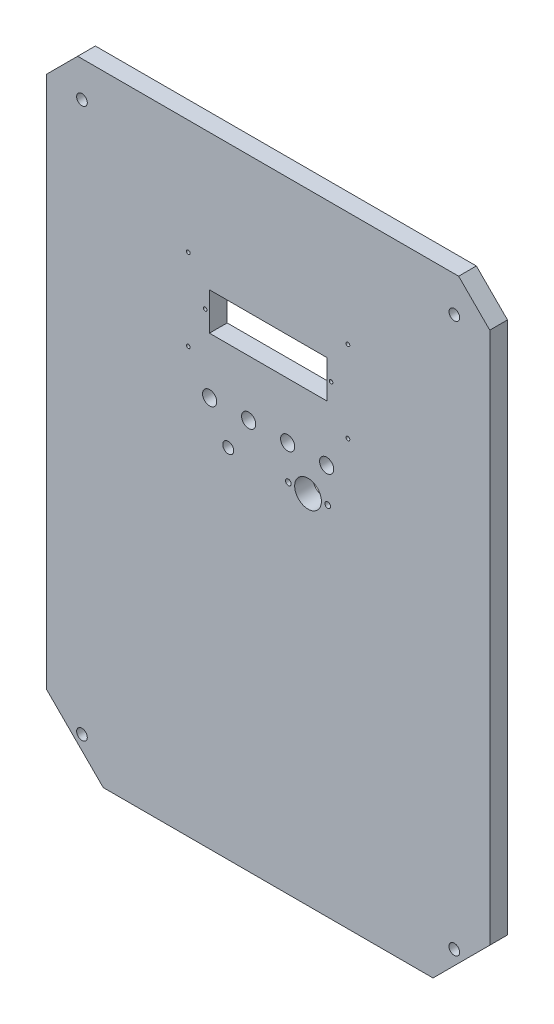
from build123d import *

# Parameters (mm, degrees)
ESQUISSE1_R        = 3
ESQUISSE1_R_2      = 1.05
ESQUISSE1_R_3      = 1
ESQUISSE1_R_4      = 7.55
ESQUISSE1_R_5      = 4
ESQUISSE1_R_6      = 1.6
ESQUISSE1_R_7      = 3.1
ESQUISSE1_W        = 66.2
ESQUISSE1_H        = 21.2
BOSS_EXTRU_1_DEPTH = 10


with BuildPart() as part:
    # Esquisse1 → Boss.-Extru.1 (new body)
    with BuildSketch(Plane.XY):
        Polygon((907.601426779, 522.610093658), (939.601426779, 554.610093658), (939.601426779, 855.042708993), (922.034042113, 872.610093658), (707.168811445, 872.610093658), (689.601426779, 855.042708993), (689.601426779, 554.610093658), (721.601426779, 522.610093658), align=None)
        with Locations((709.601426779, 542.610093658)):
            Circle(ESQUISSE1_R, mode=Mode.SUBTRACT)
        with Locations((709.601426779, 852.610093658)):
            Circle(ESQUISSE1_R, mode=Mode.SUBTRACT)
        with Locations((919.601426779, 852.610093658)):
            Circle(ESQUISSE1_R, mode=Mode.SUBTRACT)
        with Locations((919.601426779, 542.610093658)):
            Circle(ESQUISSE1_R, mode=Mode.SUBTRACT)
        with Locations((859.601426779, 808.110093658)):
            Circle(ESQUISSE1_R_2, mode=Mode.SUBTRACT)
        with Locations((769.601426779, 808.110093658)):
            Circle(ESQUISSE1_R_2, mode=Mode.SUBTRACT)
        with Locations((769.601426779, 762.110093658)):
            Circle(ESQUISSE1_R_2, mode=Mode.SUBTRACT)
        with Locations((859.601426779, 762.110093658)):
            Circle(ESQUISSE1_R_2, mode=Mode.SUBTRACT)
        with Locations((850.101426779, 785.110093658)):
            Circle(ESQUISSE1_R_3, mode=Mode.SUBTRACT)
        with Locations((779.101426779, 785.110093658)):
            Circle(ESQUISSE1_R_3, mode=Mode.SUBTRACT)
        with Locations((837.101426779, 723.920773658)):
            Circle(ESQUISSE1_R_4, mode=Mode.SUBTRACT)
        with Locations((847.601426779, 743.015433658)):
            Circle(ESQUISSE1_R_5, mode=Mode.SUBTRACT)
        with Locations((848.201426779, 723.920773658)):
            Circle(ESQUISSE1_R_6, mode=Mode.SUBTRACT)
        with Locations((826.001426779, 723.920773658)):
            Circle(ESQUISSE1_R_6, mode=Mode.SUBTRACT)
        with Locations((825.601426779, 743.015433658)):
            Circle(ESQUISSE1_R_5, mode=Mode.SUBTRACT)
        with Locations((803.601426779, 743.015433658)):
            Circle(ESQUISSE1_R_5, mode=Mode.SUBTRACT)
        with Locations((781.601426779, 743.015433658)):
            Circle(ESQUISSE1_R_5, mode=Mode.SUBTRACT)
        with Locations((792.101426779, 723.920773658)):
            Circle(ESQUISSE1_R_7, mode=Mode.SUBTRACT)
        with Locations((814.601426779, 785.110093658)):
            Rectangle(ESQUISSE1_W, ESQUISSE1_H, mode=Mode.SUBTRACT)
    extrude(amount=BOSS_EXTRU_1_DEPTH)


solid = part.part
